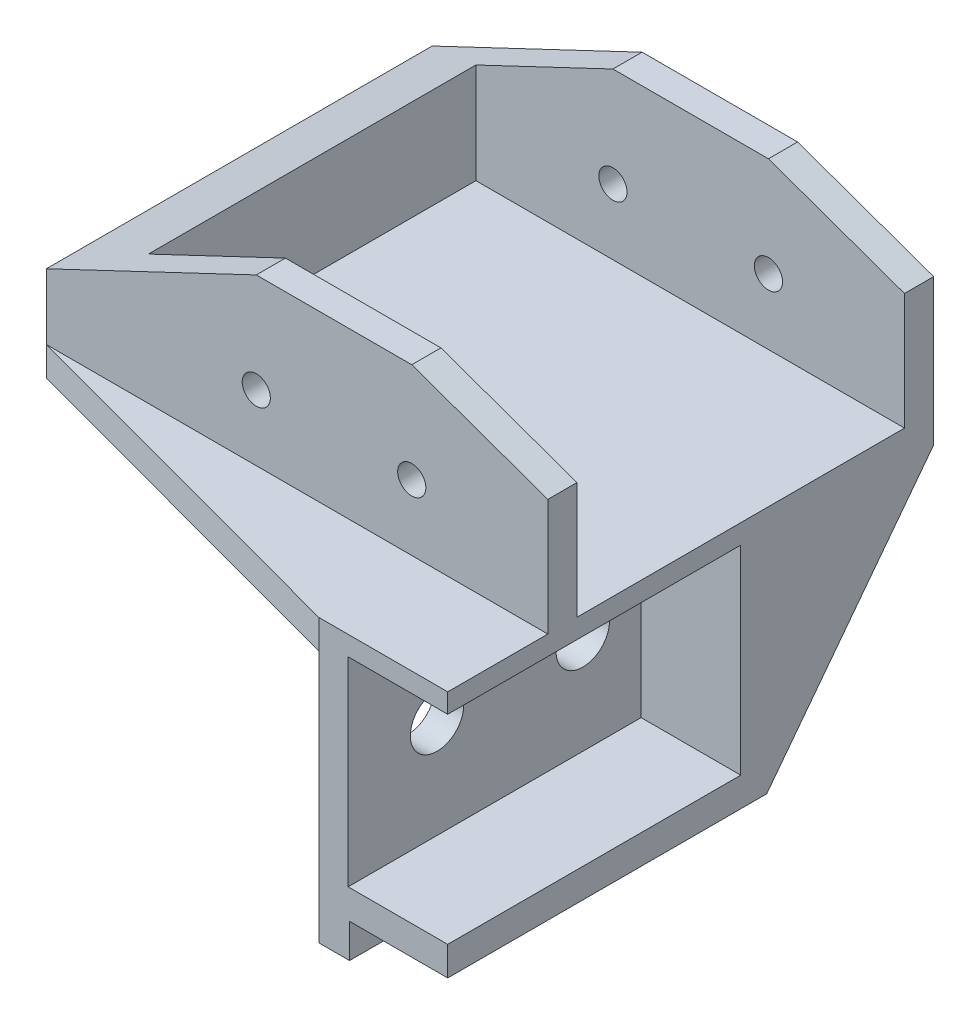
from build123d import *

# Parameters (mm, degrees)
SKETCH_1_W                     = 103.2
SKETCH_1_H                     = 20
EXTRUDE_1_DEPTH                = 39.7
SKETCH_2_W                     = 88.2
SKETCH_2_H                     = 33.7
CUT_EXTRUDE_1_DEPTH            = 17
EXTRUDE_START                  = -3
SKETCH_3_W                     = 26.5
SKETCH_3_H                     = 50
EXTRUDE_2_DEPTH                = 29
SKETCH_21_W                    = 20.5
SKETCH_21_H                    = 20.5
CUT_EXTRUDE_11_DEPTH           = 30.15
SKETCH_22_W                    = 20.2
SKETCH_22_H                    = 50
CUT_EXTRUDE_12_DEPTH           = 3.5
CUT_EXTRUDE_14_DEPTH           = 65.85
EXTRUDE_4_DEPTH                = 3
HOLE_WIZARD_M2_5_1_D           = 2.9
HOLE_WIZARD_M2_5_1_CSINK_D     = 2.95
HOLE_WIZARD_M2_5_1_CSINK_ANGLE = 90
HOLE_WIZARD_M5_2_D             = 5.5
HOLE_WIZARD_M5_2_CSINK_D       = 5.55
HOLE_WIZARD_M5_2_CSINK_ANGLE   = 90
CUT_EXTRUDE_19_DEPTH           = 51
SKETCH_36_W                    = 50
SKETCH_36_H                    = 46
CUT_EXTRUDE_20_DEPTH           = 51.6


with BuildPart() as part:
    # 草图1 → 凸台-拉伸1 (new body)
    with BuildSketch(Plane.XY):
        with Locations((-51.6, 10)):
            Rectangle(SKETCH_1_W, SKETCH_1_H)
    extrude(amount=EXTRUDE_1_DEPTH)

    # 草图2 → 切除-拉伸1 (cut)
    with BuildSketch(Plane(origin=(0, 20, 0), x_dir=(1, 0, 0), z_dir=(0, 1, 0))):
        with Locations((-51.6, -19.85)):
            Rectangle(SKETCH_2_W, SKETCH_2_H)
    extrude(amount=-CUT_EXTRUDE_1_DEPTH, mode=Mode.SUBTRACT)

    # 草图3 → 凸台-拉伸2 (add)
    with BuildSketch(Plane.XZ.offset(EXTRUDE_START)):
        with Locations((-51.6, 25)):
            Rectangle(SKETCH_3_W, SKETCH_3_H)
    extrude(amount=EXTRUDE_2_DEPTH)

    # 草图21 → 切除-拉伸11 (cut)
    with BuildSketch(Plane.XY.offset(50)):
        with Locations((-51.6, -9.25)):
            Rectangle(SKETCH_21_W, SKETCH_21_H)
    extrude(amount=-CUT_EXTRUDE_11_DEPTH, mode=Mode.SUBTRACT)

    # 草图22 → 切除-拉伸12 (cut)
    with BuildSketch(Plane.XZ.offset(26)):
        with Locations((-51.6, 25)):
            Rectangle(SKETCH_22_W, SKETCH_22_H)
    extrude(amount=-CUT_EXTRUDE_12_DEPTH, mode=Mode.SUBTRACT)

    # 草图24 → 切除-拉伸14 (cut, through all)
    with BuildSketch(Plane(origin=(-38.35, 0, 0), x_dir=(0, 0, -1), z_dir=(1, 0, 0))):
        Polygon((0, 0), (0, -26), (-19.85, -26), align=None)
    extrude(amount=-CUT_EXTRUDE_14_DEPTH, mode=Mode.SUBTRACT)

    # 草图25 → 凸台-拉伸4 (add)
    with BuildSketch(Plane.XZ):
        Polygon((-38.35, 39.7), (-38.35, 50), (0, 39.7), align=None)
        Polygon((-64.85, 39.7), (-103.2, 39.7), (-64.85, 50), align=None)
    extrude(amount=-EXTRUDE_4_DEPTH)

    # M2.5 间隙孔1 (through all)
    with Locations(Plane(origin=(0, 0, 0), x_dir=(-1, 0, 0), z_dir=(0, 0, -1))):
        with Locations((81.6, 9.75), (37.6, 9.75), (21.6, 9.75), (65.6, 9.75)):
            CounterSinkHole(HOLE_WIZARD_M2_5_1_D / 2, HOLE_WIZARD_M2_5_1_CSINK_D / 2, counter_sink_angle=HOLE_WIZARD_M2_5_1_CSINK_ANGLE)

    # M5 间隙孔2 (through all)
    with Locations(Plane(origin=(-38.35, 0, 0), x_dir=(0, 0, -1), z_dir=(1, 0, 0))):
        with Locations((-40.85, -9.25), (-25.85, -9.25)):
            CounterSinkHole(HOLE_WIZARD_M5_2_D / 2, HOLE_WIZARD_M5_2_CSINK_D / 2, counter_sink_angle=HOLE_WIZARD_M5_2_CSINK_ANGLE)

    # 草图35 → 切除-拉伸19 (cut, through all)
    with BuildSketch(Plane(origin=(0, 0, 0), x_dir=(-1, 0, 0), z_dir=(0, 0, -1))):
        Polygon((103.2, 20), (81.6, 20), (103.2, 9.75), align=None)
        Polygon((0, 20), (0, 9.75), (21.6, 20), align=None)
        Polygon((65.6, 20), (51.6, 15), (37.6, 20), align=None)
    extrude(amount=-CUT_EXTRUDE_19_DEPTH, mode=Mode.SUBTRACT)

    # 草图36 → 切除-拉伸20 (cut)
    with BuildSketch(Plane.ZY.offset(51.6)):
        with Locations((25, -3)):
            Rectangle(SKETCH_36_W, SKETCH_36_H)
    extrude(amount=-CUT_EXTRUDE_20_DEPTH, mode=Mode.SUBTRACT)


solid = part.part
